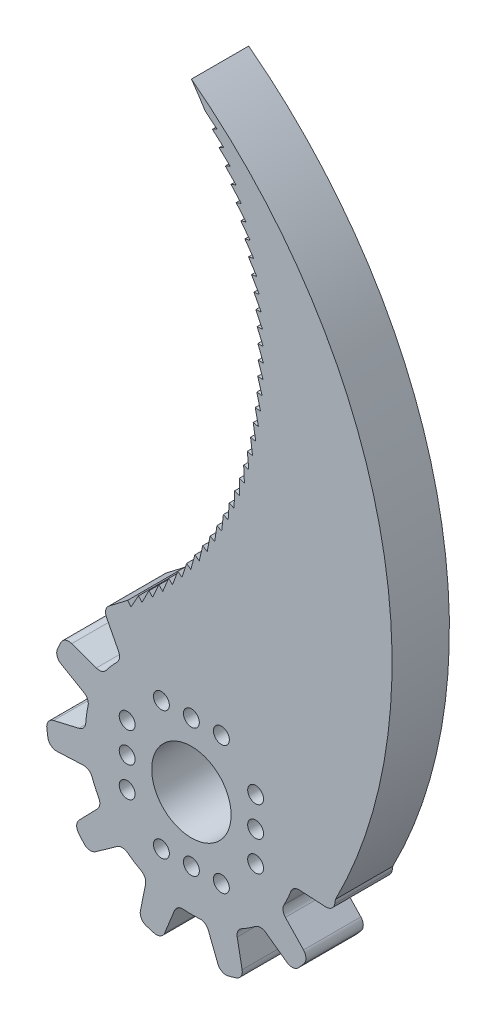
from build123d import *

# Parameters (mm, degrees)
ESBO_O1_R                = 4.5
RESSALTO_EXTRUS_O1_DEPTH = 6.5
ESBO_O3_R                = 0.9
CORTE_EXTRUS_O4_DEPTH    = 11.8
ESBO_O5_W                = 1.8
ESBO_O5_H                = 6.8
CORTE_EXTRUS_O5_DEPTH    = 1
RESSALTO_EXTRUS_O2_DEPTH = 6.5


with BuildPart() as part:
    # Esboço1 → Ressalto-extrusão1 (new body)
    with BuildSketch(Plane.XY):
        with BuildLine():
            Line((7.238575118, 13.881675818), (5.386870821, 11.538137531))
            ThreePointArc((5.386870821, 11.538137531), (4.869085061, 11.194360669), (4.248220881, 11.22286146))
            ThreePointArc((4.248220881, 11.22286146), (3.381303753, 11.51376502), (2.494752282, 11.73781117))
            ThreePointArc((2.494752282, 11.73781117), (1.95352163, 12.053535331), (1.706407374, 12.629336432))
            Line((1.706407374, 12.629336432), (1.449855219, 15.579821668))
            ThreePointArc((1.449855219, 15.579821668), (1.140115262, 16.220324883), (0.482880037, 16.492767665))
            ThreePointArc((0.482880037, 16.492767665), (0.017753421, 16.499825551), (-0.447387306, 16.493768611))
            ThreePointArc((-0.447387306, 16.493768611), (-1.102064396, 16.225682601), (-1.415523672, 15.591477992))
            Line((-1.415523672, 15.591477992), (-1.706263998, 12.618861205))
            ThreePointArc((-1.706263998, 12.618861205), (-1.955993294, 12.049721588), (-2.493706169, 11.738033461))
            ThreePointArc((-2.493706169, 11.738033461), (-3.380277605, 11.514066324), (-4.247220655, 11.223240027))
            ThreePointArc((-4.247220655, 11.223240027), (-4.873226221, 11.196232711), (-5.392413541, 11.547027368))
            Line((-5.392413541, 11.547027368), (-7.203391697, 13.89043093))
            ThreePointArc((-7.203391697, 13.89043093), (-7.810243712, 14.261798458), (-8.510438855, 14.135663723))
            ThreePointArc((-8.510438855, 14.135663723), (-8.905544045, 13.89013476), (-9.293570696, 13.633565275))
            ThreePointArc((-9.293570696, 13.633565275), (-9.699381872, 13.054091814), (-9.620203697, 12.351096068))
            Line((-9.620203697, 12.351096068), (-8.257672053, 9.693185606))
            ThreePointArc((-8.257672053, 9.693185606), (-8.160057598, 9.079381042), (-8.443899131, 8.526462776))
            ThreePointArc((-8.443899131, 8.526462776), (-9.068644707, 7.858732925), (-9.640731044, 7.145369476))
            ThreePointArc((-9.640731044, 7.145369476), (-10.15275918, 6.784205315), (-10.779181257, 6.798618702))
            Line((-10.779181257, 6.798618702), (-13.569612646, 7.790926517))
            ThreePointArc((-13.569612646, 7.790926517), (-14.280905492, 7.775251792), (-14.801753543, 7.290586426))
            ThreePointArc((-14.801753543, 7.290586426), (-15.001394201, 6.870424326), (-15.189111056, 6.444801295))
            ThreePointArc((-15.189111056, 6.444801295), (-15.217214136, 5.737919113), (-14.770537021, 5.189328411))
            Line((-14.770537021, 5.189328411), (-12.187327578, 3.689992067))
            ThreePointArc((-12.187327578, 3.689992067), (-11.773361272, 3.226401167), (-11.71321378, 2.607800404))
            ThreePointArc((-11.71321378, 2.607800404), (-11.87778119, 1.708307349), (-11.973377444, 0.798894602))
            ThreePointArc((-11.973377444, 0.798894602), (-12.208862836, 0.218240666), (-12.743635086, -0.108303365))
            Line((-12.743635086, -0.108303365), (-15.627577459, -0.782142017))
            ThreePointArc((-15.627577459, -0.782142017), (-16.217480682, -1.17988238), (-16.393616066, -1.869200548))
            ThreePointArc((-16.393616066, -1.869200548), (-16.334407693, -2.330597288), (-16.262215977, -2.79014156))
            ThreePointArc((-16.262215977, -2.79014156), (-15.903688431, -3.400002365), (-15.231329205, -3.620014351))
            Line((-15.231329205, -3.620014351), (-12.247592708, -3.484747882))
            ThreePointArc((-12.247592708, -3.484747882), (-11.648705927, -3.650938282), (-11.263665815, -4.13882017))
            ThreePointArc((-11.263665815, -4.13882017), (-10.91580607, -4.984493739), (-10.504561105, -5.801223662))
            ThreePointArc((-10.504561105, -5.801223662), (-10.388738804, -6.417013853), (-10.662074818, -6.980839878))
            Line((-10.662074818, -6.980839878), (-12.723896847, -9.106885987))
            ThreePointArc((-12.723896847, -9.106885987), (-13.005120343, -9.760412234), (-12.780621319, -10.435529556))
            ThreePointArc((-12.780621319, -10.435529556), (-12.481362156, -10.79167073), (-12.172182228, -11.139234184))
            ThreePointArc((-12.172182228, -11.139234184), (-11.54085402, -11.458447115), (-10.856281986, -11.280028134))
            Line((-10.856281986, -11.280028134), (-8.419333691, -9.553105))
            ThreePointArc((-8.419333691, -9.553105), (-7.825668757, -9.369130623), (-7.23798354, -9.571394584))
            ThreePointArc((-7.23798354, -9.571394584), (-6.48813965, -10.094753285), (-5.700620838, -10.559494404))
            ThreePointArc((-5.700620838, -10.559494404), (-5.270263606, -11.014911813), (-5.195381129, -11.637009055))
            Line((-5.195381129, -11.637009055), (-5.78046889, -14.540258003))
            ThreePointArc((-5.78046889, -14.540258003), (-5.663726185, -15.242080167), (-5.109869607, -15.688651663))
            ThreePointArc((-5.109869607, -15.688651663), (-4.665572323, -15.826464965), (-4.217566627, -15.95169866))
            ThreePointArc((-4.217566627, -15.95169866), (-3.513880001, -15.878915868), (-3.034441943, -15.358712685))
            Line((-3.034441943, -15.358712685), (-1.917995715, -12.58841878))
            ThreePointArc((-1.917995715, -12.58841878), (-1.51803705, -12.11269019), (-0.914292632, -11.965118845))
            ThreePointArc((-0.914292632, -11.965118845), (-0.000534735, -11.999999988), (0.913226267, -11.965200282))
            ThreePointArc((0.913226267, -11.965200282), (1.521483049, -12.115653101), (1.920809359, -12.59851008))
            Line((1.920809359, -12.59851008), (2.998217098, -15.357200839))
            ThreePointArc((2.998217098, -15.357200839), (3.47586102, -15.884495343), (4.183229601, -15.960737718))
            ThreePointArc((4.183229601, -15.960737718), (4.631503757, -15.836468399), (5.076096579, -15.699611521))
            ThreePointArc((5.076096579, -15.699611521), (5.62872609, -15.257941027), (5.750811977, -14.561114479))
            Line((5.750811977, -14.561114479), (5.192292349, -11.626998542))
            ThreePointArc((5.192292349, -11.626998542), (5.271560694, -11.010556206), (5.699679727, -10.560002415))
            ThreePointArc((5.699679727, -10.560002415), (6.487239956, -10.095331483), (7.237130485, -9.572039612))
            ThreePointArc((7.237130485, -9.572039612), (7.830169587, -9.369760134), (8.427156447, -9.560073171))
            Line((8.427156447, -9.560073171), (10.824990341, -11.298340917))
            ThreePointArc((10.824990341, -11.298340917), (11.511886909, -11.483695481), (12.148182967, -11.165402321))
            ThreePointArc((12.148182967, -11.165402321), (12.458110118, -10.818505011), (12.758134987, -10.463008652))
            ThreePointArc((12.758134987, -10.463008652), (12.984251418, -9.792677718), (12.710223727, -9.140465309))
            Line((12.710223727, -9.140465309), (10.654064278, -6.97408842))
            ThreePointArc((10.654064278, -6.97408842), (10.387475166, -6.412648424), (10.504044045, -5.802159831))
            ThreePointArc((10.504044045, -5.802159831), (10.915361797, -4.985466563), (11.263296909, -4.139823999))
            ThreePointArc((11.263296909, -4.139823999), (11.652832606, -3.649034528), (12.257940907, -3.486380579))
            Line((12.257940907, -3.486380579), (15.214905637, -3.652337585))
            ThreePointArc((15.214905637, -3.652337585), (15.892970044, -3.436903445), (16.256174077, -2.825130578))
            ThreePointArc((16.256174077, -2.825130578), (16.329354542, -2.365742722), (16.389555681, -1.904474464))
            ThreePointArc((16.389555681, -1.904474464), (16.217368664, -1.218308425), (15.63422925, -0.817782987))
            Line((15.63422925, -0.817782987), (12.733246078, -0.106954501))
            ThreePointArc((12.733246078, -0.106954501), (12.205439666, 0.221229924), (11.973448596, 0.797827503))
            ThreePointArc((11.973448596, 0.797827503), (11.877933391, 1.707248766), (11.713446147, 2.606756484))
            ThreePointArc((11.713446147, 2.606756484), (11.775803607, 3.230233757), (12.19691574, 3.694213214))
            Line((12.19691574, 3.694213214), (14.774195896, 5.153257125))
            ThreePointArc((14.774195896, 5.153257125), (15.228147485, 5.701081152), (15.202944777, 6.412100162))
            ThreePointArc((15.202944777, 6.412100162), (15.016144277, 6.838126166), (14.817408249, 7.25871691))
            ThreePointArc((14.817408249, 7.25871691), (14.301585944, 7.742865184), (13.594477452, 7.764539655))
            Line((13.594477452, 7.764539655), (10.769712216, 6.794136716))
            ThreePointArc((10.769712216, 6.794136716), (10.148263312, 6.784869333), (9.641367818, 7.144510242))
            ThreePointArc((9.641367818, 7.144510242), (9.06934506, 7.857924674), (8.444658996, 8.525710201))
            ThreePointArc((8.444658996, 8.525710201), (8.160040167, 9.083925649), (8.263456004, 9.701920413))
            Line((8.263456004, 9.701920413), (9.642783348, 12.322729108))
            ThreePointArc((9.642783348, 12.322729108), (9.728495696, 13.029012764), (9.32288793, 13.613534407))
            ThreePointArc((9.32288793, 13.613534407), (8.935414302, 13.870938312), (8.540838393, 14.117316952))
            ThreePointArc((8.540838393, 14.117316952), (7.845150738, 14.245733807), (7.238575118, 13.881675818))
        make_face()
        Circle(ESBO_O1_R, mode=Mode.SUBTRACT)
    extrude(amount=RESSALTO_EXTRUS_O1_DEPTH)

    # Esboço3 → Corte-extrusão4 (cut)
    with BuildSketch(Plane(origin=(0, 0, 0), x_dir=(-1, 0, 0), z_dir=(0, 0, -1))):
        with Locations((3.4, 7.28)):
            Circle(ESBO_O3_R)
        with Locations((0, 7.28)):
            Circle(ESBO_O3_R)
        with Locations((-3.4, 7.28)):
            Circle(ESBO_O3_R)
        with Locations((7.28, -3.4)):
            Circle(ESBO_O3_R)
        with Locations((7.28, 0)):
            Circle(ESBO_O3_R)
        with Locations((7.28, 3.4)):
            Circle(ESBO_O3_R)
        with Locations((-3.4, -7.28)):
            Circle(ESBO_O3_R)
        with Locations((0, -7.28)):
            Circle(ESBO_O3_R)
        with Locations((3.4, -7.28)):
            Circle(ESBO_O3_R)
        with Locations((-7.28, 3.4)):
            Circle(ESBO_O3_R)
        with Locations((-7.28, 0)):
            Circle(ESBO_O3_R)
        with Locations((-7.28, -3.4)):
            Circle(ESBO_O3_R)
    extrude(amount=-CORTE_EXTRUS_O4_DEPTH, mode=Mode.SUBTRACT)

    # Esboço5 → Corte-extrusão5 (cut)
    with BuildSketch(Plane(origin=(0, 0, 0), x_dir=(-1, 0, 0), z_dir=(0, 0, -1))):
        with Locations((7.28, 0)):
            Rectangle(ESBO_O5_W, ESBO_O5_H)
        with Locations((-7.28, 0)):
            Rectangle(ESBO_O5_W, ESBO_O5_H)
    extrude(amount=-CORTE_EXTRUS_O5_DEPTH, mode=Mode.SUBTRACT)

    # Esboço6 → Ressalto-extrusão2 (add)
    with BuildSketch(Plane.XY.offset(6.5)):
        with BuildLine():
            Line((7.838617306, 41.301876791), (7.244086844, 41.38270704))
            Line((7.244086844, 41.38270704), (7.242511813, 41.370299845))
            Line((7.242511813, 41.370299845), (7.600390495, 39.68396948))
            Line((7.600390495, 39.68396948), (7.009556784, 39.788446874))
            Line((7.009556784, 39.788446874), (7.007488174, 39.776112368))
            Line((7.007488174, 39.776112368), (7.297826778, 38.076850543))
            Line((7.297826778, 38.076850543), (6.711629988, 38.204808831))
            Line((6.711629988, 38.204808831), (6.709071091, 38.19256664))
            Line((6.709071091, 38.19256664), (6.931407612, 36.483077324))
            Line((6.931407612, 36.483077324), (6.350780535, 36.634312891))
            Line((6.350780535, 36.634312891), (6.347735423, 36.622182496))
            Line((6.347735423, 36.622182496), (6.501716066, 34.905185928))
            Line((6.501716066, 34.905185928), (5.92758263, 35.079458121))
            Line((5.92758263, 35.079458121), (5.924056148, 35.067458824))
            Line((5.924056148, 35.067458824), (6.009435891, 33.345687192))
            Line((6.009435891, 33.345687192), (5.44270969, 33.542718696))
            Line((5.44270969, 33.542718696), (5.43870745, 33.530869592))
            Line((5.43870745, 33.530869592), (5.455350431, 31.807062682))
            Line((5.455350431, 31.807062682), (4.896933275, 32.02653997))
            Line((4.896933275, 32.02653997), (4.892461646, 32.014859914))
            Line((4.892461646, 32.014859914), (4.84034138, 30.291760749))
            Line((4.84034138, 30.291760749), (4.291121856, 30.533334576))
            Line((4.291121856, 30.533334576), (4.286187953, 30.521842153))
            Line((4.286187953, 30.521842153), (4.165387379, 28.802192632))
            Line((4.165387379, 28.802192632), (3.626239436, 29.065478591))
            Line((3.626239436, 29.065478591), (3.62085111, 29.054192088))
            Line((3.62085111, 29.054192088), (3.431562453, 27.34072862))
            Line((3.431562453, 27.34072862), (2.903344016, 27.625307754))
            Line((2.903344016, 27.625307754), (2.897509842, 27.614245133))
            Line((2.897509842, 27.614245133), (2.640034308, 25.909694282))
            Line((2.640034308, 25.909694282), (2.123585911, 26.215113753))
            Line((2.123585911, 26.215113753), (2.117315171, 26.204292615))
            Line((2.117315171, 26.204292615), (1.792062472, 24.511366765))
            Line((1.792062472, 24.511366765), (1.288205917, 24.83714057))
            Line((1.288205917, 24.83714057), (1.281508591, 24.826578136))
            Line((1.281508591, 24.826578136), (0.888996287, 23.147971171))
            Line((0.888996287, 23.147971171), (0.398533341, 23.49358092))
            Line((0.398533341, 23.49358092), (0.391420086, 23.483293997))
            Line((0.391420086, 23.483293997), (-0.067727233, 21.821677016))
            Line((-0.067727233, 21.821677016), (-0.544016116, 22.186572755))
            Line((-0.544016116, 22.186572755), (-0.551533982, 22.176577711))
            Line((-0.551533982, 22.176577711), (-1.076585694, 20.534594778))
            Line((-1.076585694, 20.534594778), (-1.537942615, 20.918195862))
            Line((-1.537942615, 20.918195862), (-1.545853128, 20.908508604))
            Line((-1.545853128, 20.908508604), (-2.13597374, 19.28877254))
            Line((-2.13597374, 19.28877254), (-2.58166456, 19.690468561))
            Line((-2.58166456, 19.690468561), (-2.589955133, 19.681104502))
            Line((-2.589955133, 19.681104502), (-3.244205608, 18.086192728))
            Line((-3.244205608, 18.086192728), (-3.673521118, 18.505344482))
            Line((-3.673521118, 18.505344482), (-3.682178558, 18.496318524))
            Line((-3.682178558, 18.496318524), (-4.399517816, 16.928768958))
            Line((-4.399517816, 16.928768958), (-4.811774863, 17.364709467))
            Line((-4.811774863, 17.364709467), (-4.820785394, 17.356035972))
            Line((-4.820785394, 17.356035972), (-5.600071961, 15.818342992))
            Line((-5.600071961, 15.818342992), (-5.994614537, 16.270378561))
            Line((-5.994614537, 16.270378561), (-6.003963821, 16.262071331))
            Line((-6.003963821, 16.262071331), (-6.843957649, 14.756681807))
            Line((-6.843957649, 14.756681807), (-7.220157935, 15.22409313))
            Line((-7.220157935, 15.22409313), (-9.293570696, 13.633565275))
            Line((-9.293570696, 13.633565275), (-6.195775684, 9.089134304))
            ThreePointArc((-6.195775684, 9.089134304), (5.140353419, 9.725058634), (10.999999942, 0))
            ThreePointArc((10.999999942, 0), (10.971549439, -0.790633687), (10.8863451, -1.577177568))
            Line((10.8863451, -1.577177568), (16.329354542, -2.365742722))
            ThreePointArc((16.329354542, -2.365742722), (21.334201879, 36.788836361), (0, 70))
            ThreePointArc((0, 70), (0.805858517, 68.833178417), (1.570266841, 67.638791349))
            Line((1.570266841, 67.638791349), (2.906922718, 66.550150767))
            Line((2.906922718, 66.550150767), (2.381285929, 66.260830933))
            ThreePointArc((2.381285929, 66.260830933), (2.384350141, 66.255379749), (2.387413509, 66.249928091))
            Line((2.387413509, 66.249928091), (3.679588022, 65.108844273))
            Line((3.679588022, 65.108844273), (3.1428306, 64.840718424))
            ThreePointArc((3.1428306, 64.840718424), (3.145674966, 64.835149368), (3.14851847, 64.829579872))
            Line((3.14851847, 64.829579872), (4.394155433, 63.637868578))
            Line((4.394155433, 63.637868578), (3.847131501, 63.391363372))
            ThreePointArc((3.847131501, 63.391363372), (3.849751495, 63.385685306), (3.85237061, 63.380006835))
            Line((3.85237061, 63.380006835), (5.049487891, 62.139564387))
            Line((5.049487891, 62.139564387), (4.493067904, 61.915072076))
            ThreePointArc((4.493067904, 61.915072076), (4.495459357, 61.909294036), (4.497849916, 61.903515626))
            Line((4.497849916, 61.903515626), (5.644542592, 60.61631589))
            Line((5.644542592, 60.61631589), (5.079611958, 60.414193701))
            ThreePointArc((5.079611958, 60.414193701), (5.081771065, 60.40832488), (5.083929263, 60.402455726))
            Line((5.083929263, 60.402455726), (6.178372648, 59.070546971))
            Line((6.178372648, 59.070546971), (5.605830319, 58.891116532))
            ThreePointArc((5.605830319, 58.891116532), (5.607753644, 58.88516627), (5.609676048, 58.87921571))
            Line((5.609676048, 58.87921571), (6.650128597, 57.504717349))
            Line((6.650128597, 57.504717349), (6.070885638, 57.348264182))
            ThreePointArc((6.070885638, 57.348264182), (6.07257012, 57.342241946), (6.07425367, 57.336219451))
            Line((6.07425367, 57.336219451), (7.059059755, 55.921318666))
            Line((7.059059755, 55.921318666), (6.474037889, 55.788091727))
            ThreePointArc((6.474037889, 55.788091727), (6.475480849, 55.782007102), (6.476922866, 55.775922253))
            Line((6.476922866, 55.775922253), (7.404515403, 54.322870521))
            Line((7.404515403, 54.322870521), (6.814645554, 54.213081809))
            ThreePointArc((6.814645554, 54.213081809), (6.815844695, 54.206944475), (6.817042885, 54.200806956))
            Line((6.817042885, 54.200806956), (7.685945835, 52.711916458))
            Line((7.685945835, 52.711916458), (7.092166638, 52.625740675))
            ThreePointArc((7.092166638, 52.625740675), (7.093120051, 52.6195604), (7.094072507, 52.613379977))
            Line((7.094072507, 52.613379977), (7.902903219, 51.091019924))
            Line((7.902903219, 51.091019924), (7.306159531, 51.028594199))
            ThreePointArc((7.306159531, 51.028594199), (7.3068657, 51.022380816), (7.307570907, 51.016167324))
            Line((7.307570907, 51.016167324), (8.055042322, 49.462760186))
            Line((8.055042322, 49.462760186), (7.456283717, 49.424183854))
            ThreePointArc((7.456283717, 49.424183854), (7.456741518, 49.417947251), (7.457198353, 49.411710578))
            Line((7.457198353, 49.411710578), (8.142121049, 47.829728229))
            Line((8.142121049, 47.829728229), (7.542300308, 47.815062674))
            ThreePointArc((7.542300308, 47.815062674), (7.542509012, 47.808812775), (7.542716748, 47.802562844))
            Line((7.542716748, 47.802562844), (8.164000837, 46.194522628))
            Line((8.164000837, 46.194522628), (7.56407243, 46.203791189))
            ThreePointArc((7.56407243, 46.203791189), (7.564031705, 46.197537939), (7.563990012, 46.191284695))
            Line((7.563990012, 46.191284695), (8.120646868, 44.559745422))
            Line((8.120646868, 44.559745422), (7.521565437, 44.592933349))
            ThreePointArc((7.521565437, 44.592933349), (7.521275348, 44.586686698), (7.520984293, 44.580440092))
            Line((7.520984293, 44.580440092), (8.012128131, 42.927997965))
            Line((8.012128131, 42.927997965), (7.414846969, 42.985052447))
            ThreePointArc((7.414846969, 42.985052447), (7.414307978, 42.978822336), (7.413768023, 42.972592308))
            Line((7.413768023, 42.972592308), (7.838617306, 41.301876791))
        make_face()
    extrude(amount=-RESSALTO_EXTRUS_O2_DEPTH)


solid = part.part
